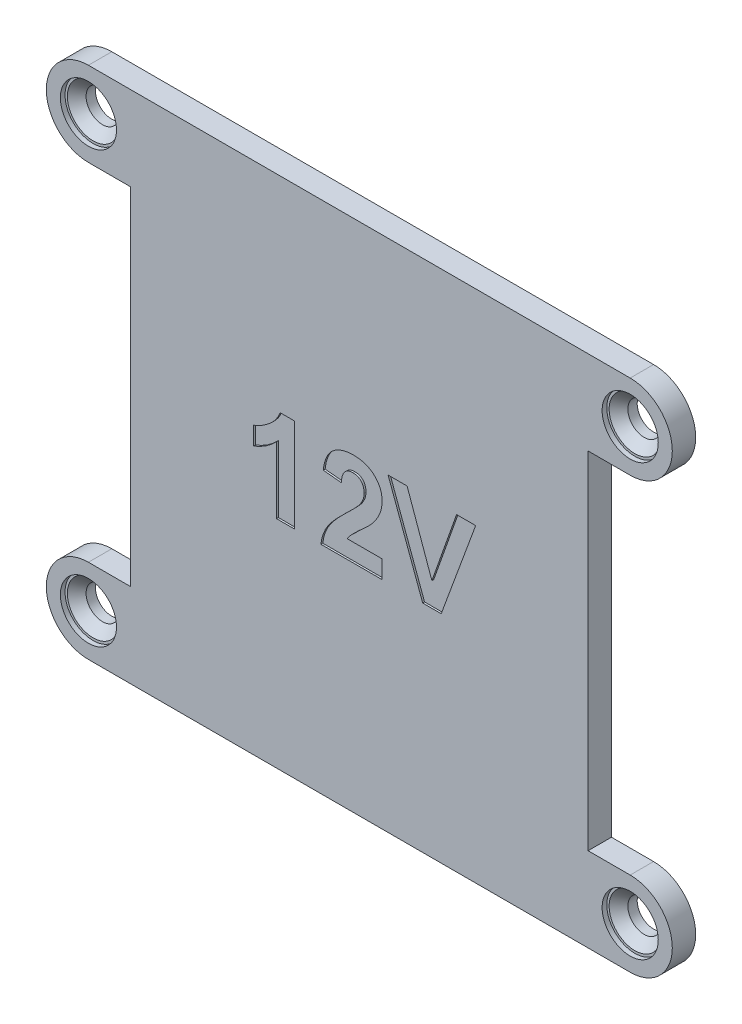
from build123d import *

# Parameters (mm, degrees)
SKETCH1_R           = 1.75
BOSS_EXTRUDE1_DEPTH = 2.5
CUT_EXTRUDE1_DEPTH  = 0.2
SKETCH5_R           = 3
CUT_EXTRUDE2_DEPTH  = 0.5
CHAMFER2_SIZE       = 1


with BuildPart() as part:
    # Sketch1 → Boss-Extrude1 (new body)
    with BuildSketch(Plane.XY):
        with BuildLine():
            ThreePointArc((-28.95, 27.5), (-33.45, 23), (-28.95, 18.5))
            Line((-28.95, 18.5), (-24.45, 18.5))
            Line((-24.45, 18.5), (-24.45, -18.5))
            Line((-24.45, -18.5), (-28.95, -18.5))
            ThreePointArc((-28.95, -18.5), (-33.45, -23), (-28.95, -27.5))
            Line((-28.95, -27.5), (28.95, -27.5))
            ThreePointArc((28.95, -27.5), (33.45, -23), (28.95, -18.5))
            Line((28.95, -18.5), (24.45, -18.5))
            Line((24.45, -18.5), (24.45, 18.5))
            Line((24.45, 18.5), (28.95, 18.5))
            ThreePointArc((28.95, 18.5), (33.45, 23), (28.95, 27.5))
            Line((28.95, 27.5), (-28.95, 27.5))
        make_face()
        with Locations((-28.95, -23)):
            Circle(SKETCH1_R, mode=Mode.SUBTRACT)
        with Locations((-28.95, 23)):
            Circle(SKETCH1_R, mode=Mode.SUBTRACT)
        with Locations((28.95, 23)):
            Circle(SKETCH1_R, mode=Mode.SUBTRACT)
        with Locations((28.95, -23)):
            Circle(SKETCH1_R, mode=Mode.SUBTRACT)
    extrude(amount=BOSS_EXTRUDE1_DEPTH)

    # Sketch4 → Cut-Extrude1 (cut)
    with BuildSketch(Plane.XY.offset(2.5)):
        with BuildLine():
            Line((-6.923076923, -4.414458023), (-8.846153846, -4.414458023))
            Line((-8.846153846, -4.414458023), (-8.846153846, 2.704933003))
            add(Edge.make_bspline(
                [(-8.846153846, 2.704933003), (-8.933318023, 2.616445103), (-9.106463901, 2.440669737), (-9.383005145, 2.19548654), (-9.670097117, 1.967401521), (-9.970580856, 1.758581072), (-10.280528273, 1.566049869), (-10.603106853, 1.391327059), (-10.935978437, 1.231995104), (-11.166572995, 1.142953291), (-11.282051282, 1.09836249)],
                knots=[0, 0, 0, 0, 0.000372537, 0.00074002, 0.001107934, 0.001471928, 0.001837155, 0.002201986, 0.002572064, 0.002943306, 0.002943306, 0.002943306, 0.002943306], degree=3))
            Line((-11.282051282, 1.09836249), (-11.282051282, 3.021439413))
            add(Edge.make_bspline(
                [(-11.282051282, 3.021439413), (-11.153980048, 3.06946063), (-10.88593692, 3.1699653), (-10.490395403, 3.38374383), (-10.077539391, 3.648423218), (-9.730716774, 3.908012402), (-9.455353873, 4.138807932), (-9.26289614, 4.324331325), (-9.084572984, 4.514316902), (-8.927087219, 4.714896702), (-8.786304768, 4.922015444), (-8.661565378, 5.135334763), (-8.551766041, 5.355528522), (-8.494286856, 5.508866571), (-8.465544872, 5.585541977)],
                knots=[0, 0, 0, 0, 0.000409928, 0.000857948, 0.001345291, 0.001880548, 0.002156279, 0.002422637, 0.002682042, 0.002937331, 0.003186801, 0.003432796, 0.003678268, 0.003923781, 0.003923781, 0.003923781, 0.003923781], degree=3))
            Line((-8.465544872, 5.585541977), (-6.923076923, 5.585541977))
            Line((-6.923076923, 5.585541977), (-6.923076923, -4.414458023))
        make_face()
        with BuildLine():
            Line((2.435897436, -2.4913811), (2.435897436, -4.414458023))
            Line((2.435897436, -4.414458023), (-4.102564103, -4.414458023))
            add(Edge.make_bspline(
                [(-4.102564103, -4.414458023), (-4.080426387, -4.250103198), (-4.036163368, -3.921485704), (-3.899317938, -3.441458257), (-3.716676165, -2.973033485), (-3.518453211, -2.59184942), (-3.321298527, -2.285009365), (-3.142420071, -2.033582253), (-2.929024642, -1.766074598), (-2.684208836, -1.480326872), (-2.409325608, -1.175445832), (-2.102324151, -0.852564961), (-1.761740021, -0.513229981), (-1.522133018, -0.282804832), (-1.398237179, -0.163656741)],
                knots=[0, 0, 0, 0, 0.000496964, 0.00099365, 0.001492867, 0.002003586, 0.002279214, 0.0025866, 0.002928861, 0.003305405, 0.003715318, 0.004160237, 0.004641841, 0.005157509, 0.005157509, 0.005157509, 0.005157509], degree=3))
            add(Edge.make_bspline(
                [(-1.398237179, -0.163656741), (-1.299366883, -0.068219837), (-1.111146958, 0.113463921), (-0.843121421, 0.373627698), (-0.607499354, 0.612792158), (-0.399354228, 0.824759525), (-0.22349449, 1.014927025), (-0.077606865, 1.180308106), (0.040156295, 1.321576252), (0.103936924, 1.411196852), (0.132211538, 1.450926592)],
                knots=[0, 0, 0, 0, 0.000412257, 0.000784815, 0.001120524, 0.001419431, 0.001676006, 0.00189743, 0.002081082, 0.002227329, 0.002227329, 0.002227329, 0.002227329], degree=3))
            add(Edge.make_bspline(
                [(0.132211538, 1.450926592), (0.190111047, 1.547103861), (0.30179249, 1.73261867), (0.424260458, 2.024344061), (0.497770298, 2.316009192), (0.507857836, 2.510898163), (0.512820513, 2.606775951)],
                knots=[0, 0, 0, 0, 0.000336425, 0.000648925, 0.000945785, 0.00123325, 0.00123325, 0.00123325, 0.00123325], degree=3))
            add(Edge.make_bspline(
                [(0.512820513, 2.606775951), (0.509218846, 2.70654968), (0.502404775, 2.895313794), (0.445267605, 3.161694863), (0.343944107, 3.390687129), (0.204440295, 3.582993487), (0.028037447, 3.733664782), (-0.178182613, 3.844996243), (-0.417238616, 3.906548032), (-0.585261277, 3.914644013), (-0.673076923, 3.91887531)],
                knots=[0, 0, 0, 0, 0.000299149, 0.000565967, 0.000811668, 0.001045254, 0.001272527, 0.001501953, 0.00174248, 0.002005823, 0.002005823, 0.002005823, 0.002005823], degree=3))
            add(Edge.make_bspline(
                [(-0.673076923, 3.91887531), (-0.760299295, 3.914923595), (-0.928794085, 3.907289734), (-1.168261741, 3.840601371), (-1.377751743, 3.7251568), (-1.52704546, 3.593596575), (-1.627900447, 3.465663812), (-1.696619517, 3.354178836), (-1.755849991, 3.227497715), (-1.808333132, 3.087046666), (-1.84978888, 2.931216675), (-1.883174765, 2.761194545), (-1.910078959, 2.576065314), (-1.918634967, 2.447276207), (-1.923076923, 2.380413772)],
                knots=[0, 0, 0, 0, 0.000261347, 0.000504866, 0.000737962, 0.000973524, 0.001096162, 0.001225691, 0.001365471, 0.001515056, 0.001674936, 0.001848581, 0.002034706, 0.002235667, 0.002235667, 0.002235667, 0.002235667], degree=3))
            Line((-1.923076923, 2.380413772), (-3.846153846, 2.568715054))
            add(Edge.make_bspline(
                [(-3.846153846, 2.568715054), (-3.830692606, 2.698546985), (-3.80071573, 2.950270356), (-3.725907936, 3.311831909), (-3.631166636, 3.645388763), (-3.511975194, 3.950321896), (-3.373259936, 4.228570387), (-3.207945231, 4.475958944), (-3.021807349, 4.695227932), (-2.814685425, 4.886260652), (-2.5878962, 5.049664829), (-2.349921603, 5.195528131), (-2.096110944, 5.315182407), (-1.829258686, 5.413795508), (-1.549485425, 5.49260631), (-1.255497172, 5.544714943), (-0.949108314, 5.581368356), (-0.739966, 5.584129802), (-0.633012821, 5.585541977)],
                knots=[0, 0, 0, 0, 0.000392096, 0.000760212, 0.001106367, 0.001431121, 0.001741094, 0.002037223, 0.002321424, 0.002602116, 0.002880179, 0.003158798, 0.003438358, 0.003720412, 0.004011539, 0.004308966, 0.004615352, 0.004936021, 0.004936021, 0.004936021, 0.004936021], degree=3))
            add(Edge.make_bspline(
                [(-0.633012821, 5.585541977), (-0.516740897, 5.583307291), (-0.290286727, 5.57895496), (0.040296159, 5.543013371), (0.350855029, 5.480344005), (0.644105005, 5.397329559), (0.917034567, 5.286499204), (1.171918028, 5.152509913), (1.404743968, 4.990276522), (1.618982973, 4.808646307), (1.810495503, 4.608911963), (1.978243149, 4.395861516), (2.118781575, 4.169643399), (2.236714897, 3.93301496), (2.324279592, 3.682168505), (2.388083037, 3.420572552), (2.43038729, 3.147006702), (2.434040407, 2.960167431), (2.435897436, 2.865189413)],
                knots=[0, 0, 0, 0, 0.000348765, 0.000679263, 0.000995909, 0.001298314, 0.001592185, 0.001878054, 0.002160328, 0.002441705, 0.002719393, 0.002989083, 0.003253658, 0.003517047, 0.003780619, 0.004048809, 0.004324175, 0.004608884, 0.004608884, 0.004608884, 0.004608884], degree=3))
            add(Edge.make_bspline(
                [(2.435897436, 2.865189413), (2.433450826, 2.756184824), (2.428597126, 2.539936446), (2.382126554, 2.220256739), (2.311128567, 1.907948806), (2.206199134, 1.602249395), (2.073192931, 1.295825486), (1.901744746, 0.987989283), (1.702680436, 0.669456993), (1.546820928, 0.463511968), (1.466346154, 0.357176592)],
                knots=[0, 0, 0, 0, 0.000326823, 0.000648367, 0.000967129, 0.0012864, 0.001616516, 0.001967917, 0.002342489, 0.002742354, 0.002742354, 0.002742354, 0.002742354], degree=3))
            add(Edge.make_bspline(
                [(1.466346154, 0.357176592), (1.435930222, 0.318867637), (1.370786347, 0.236818733), (1.259959496, 0.111009427), (1.131520709, -0.026413994), (0.987284126, -0.178023781), (0.82248533, -0.338451015), (0.643053791, -0.51440464), (0.441093999, -0.696884043), (0.231912595, -0.890441198), (0.021821946, -1.078827655), (-0.171281651, -1.257753025), (-0.34668397, -1.416063548), (-0.496216198, -1.562498691), (-0.628673782, -1.687064362), (-0.739282513, -1.796148144), (-0.830112141, -1.887109206), (-0.955269523, -2.028894425), (-1.114518089, -2.220658992), (-1.226555966, -2.40389546), (-1.280048077, -2.4913811)],
                knots=[0, 0, 0, 0, 0.000146727, 0.000314255, 0.00050278, 0.000711046, 0.000941937, 0.00119269, 0.00146489, 0.001758378, 0.002047687, 0.002311396, 0.002548156, 0.002756422, 0.002939197, 0.0030936, 0.003222507, 0.003324651, 0.003660963, 0.003968244, 0.003968244, 0.003968244, 0.003968244], degree=3))
            Line((-1.280048077, -2.4913811), (2.435897436, -2.4913811))
        make_face()
        Polygon((6.774839744, -4.414458023), (3.076923077, 5.585541977), (5.108173077, 5.585541977), (7.756410256, -1.850355459), (10.39463141, 5.585541977), (12.435897436, 5.585541977), (8.752003205, -4.414458023), align=None)
    extrude(amount=-CUT_EXTRUDE1_DEPTH, mode=Mode.SUBTRACT)

    # Sketch5 → Cut-Extrude2 (cut)
    with BuildSketch(Plane.XY.offset(2.5)):
        with Locations((-28.95, 23)):
            Circle(SKETCH5_R)
        with Locations((28.95, 23)):
            Circle(SKETCH5_R)
        with Locations((28.95, -23)):
            Circle(SKETCH5_R)
        with Locations((-28.95, -23)):
            Circle(SKETCH5_R)
    extrude(amount=-CUT_EXTRUDE2_DEPTH, mode=Mode.SUBTRACT)

    # Chamfer2
    chamfer2_edges = [part.edges().sort_by_distance(p)[0] for p in [
        (-30.7, 23, 2),
        (27.2, 23, 2),
        (27.2, -23, 2),
        (-30.7, -23, 2),
    ]]
    chamfer(chamfer2_edges, length=CHAMFER2_SIZE)


solid = part.part
